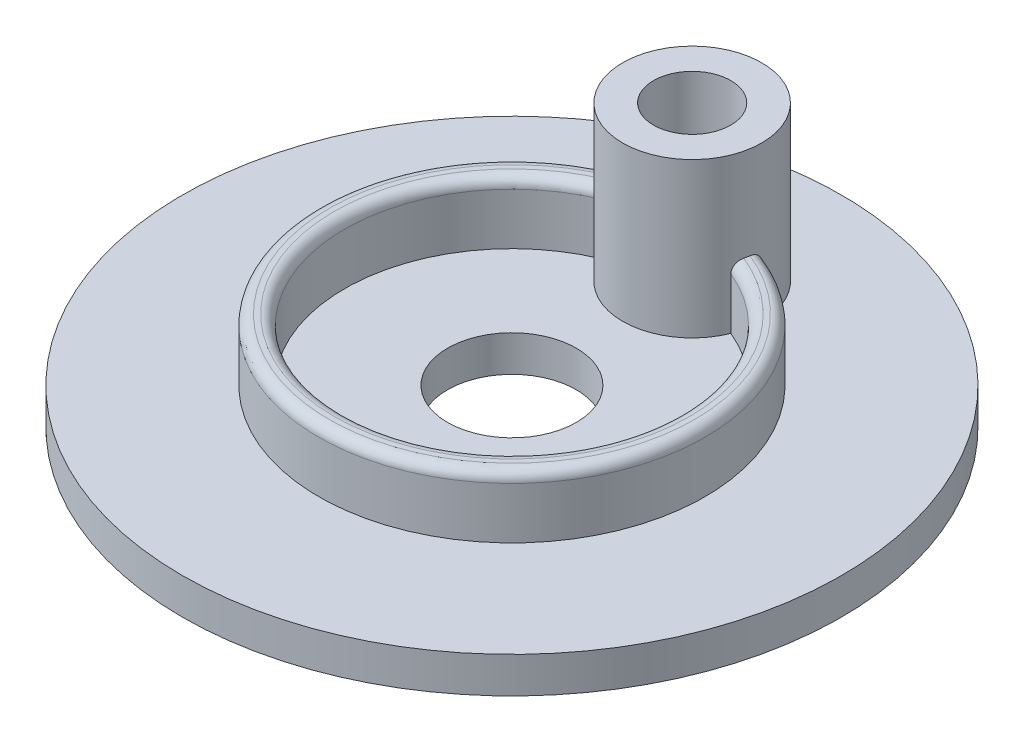
from build123d import *

# Parameters (mm, degrees)
SKETCH2_R           = 64
BOSS_EXTRUDE1_DEPTH = 7
SKETCH3_R           = 37.5
SKETCH3_R_2         = 32.5
BOSS_EXTRUDE2_DEPTH = 12
SKETCH4_R           = 12.5
CUT_EXTRUDE1_DEPTH  = 8
FILLET1_R           = 2
SKETCH5_R           = 13.5
BOSS_EXTRUDE3_DEPTH = 30
SKETCH7_R           = 7.5
CUT_EXTRUDE2_DEPTH  = 38


with BuildPart() as part:
    # Sketch2 → Boss-Extrude1 (new body)
    with BuildSketch(Plane(origin=(0, 0, 0), x_dir=(1, 0, 0), z_dir=(0, 1, 0))):
        Circle(SKETCH2_R)
    extrude(amount=BOSS_EXTRUDE1_DEPTH)

    # Sketch3 → Boss-Extrude2 (add)
    with BuildSketch(Plane(origin=(0, 7, 0), x_dir=(1, 0, 0), z_dir=(0, 1, 0))):
        Circle(SKETCH3_R)
        Circle(SKETCH3_R_2, mode=Mode.SUBTRACT)
    extrude(amount=BOSS_EXTRUDE2_DEPTH)

    # Sketch4 → Cut-Extrude1 (cut, through all)
    with BuildSketch(Plane(origin=(0, 7, 0), x_dir=(1, 0, 0), z_dir=(0, 1, 0))):
        Circle(SKETCH4_R)
    extrude(amount=-CUT_EXTRUDE1_DEPTH, mode=Mode.SUBTRACT)

    # Fillet1
    fillet1_edges = [part.edges().sort_by_distance(p)[0] for p in [
        (-37.5, 19, 0),
        (-32.5, 19, 0),
    ]]
    fillet(fillet1_edges, radius=FILLET1_R)

    # Sketch5 → Boss-Extrude3 (add)
    with BuildSketch(Plane(origin=(0, 7, 0), x_dir=(1, 0, 0), z_dir=(0, 1, 0))):
        with Locations((0, 35)):
            Circle(SKETCH5_R)
    extrude(amount=BOSS_EXTRUDE3_DEPTH)

    # Sketch7 → Cut-Extrude2 (cut, through all)
    with BuildSketch(Plane(origin=(0, 37, 0), x_dir=(1, 0, 0), z_dir=(0, 1, 0))):
        with Locations((0, 35)):
            Circle(SKETCH7_R)
    extrude(amount=-CUT_EXTRUDE2_DEPTH, mode=Mode.SUBTRACT)


solid = part.part
